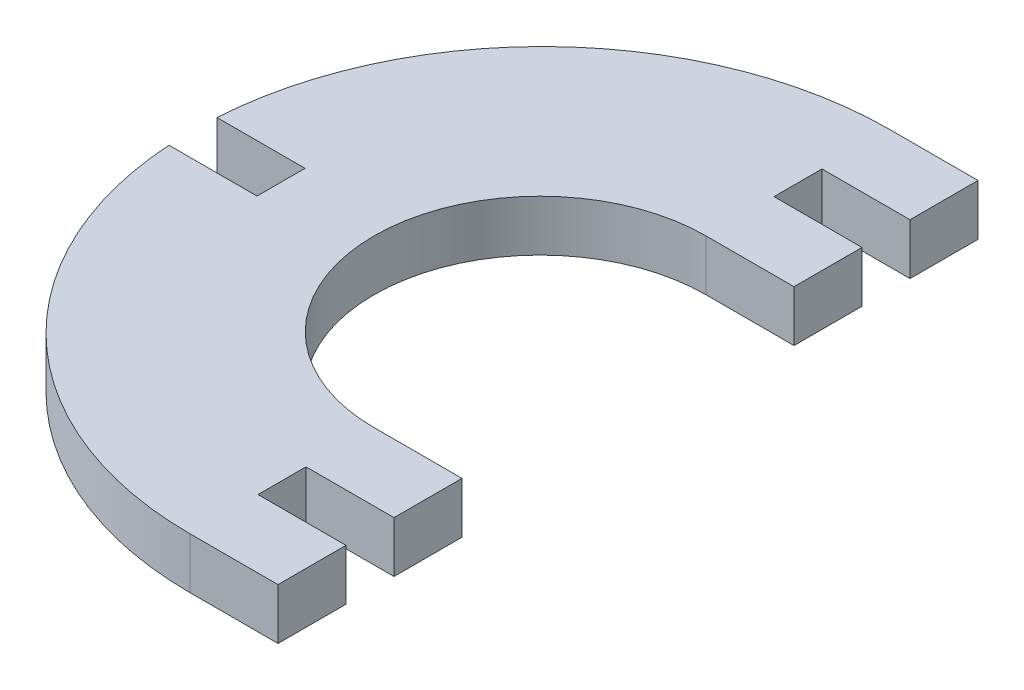
from build123d import *

# Parameters (mm, degrees)
SALIENTE_EXTRUIR1_DEPTH = 5.1


with BuildPart() as part:
    # Croquis1 → Saliente-Extruir1 (new body)
    with BuildSketch(Plane(origin=(0, 0, 0), x_dir=(1, 0, 0), z_dir=(0, 1, 0))):
        with BuildLine():
            Line((0, 0), (0, 6.8))
            Line((0, 6.8), (-8.8, 6.8))
            Line((-8.8, 6.8), (-8.8, 11.6))
            Line((-8.8, 11.6), (0, 11.6))
            Line((0, 11.6), (0, 18.4))
            Line((0, 18.4), (-8.8, 18.4))
            ThreePointArc((-8.8, 18.4), (-25.4, 35), (-8.8, 51.6))
            Line((-8.8, 51.6), (0, 51.6))
            Line((0, 51.6), (0, 58.4))
            Line((0, 58.4), (-8.8, 58.4))
            Line((-8.8, 58.4), (-8.8, 63.2))
            Line((-8.8, 63.2), (0, 63.2))
            Line((0, 63.2), (0, 70))
            Line((0, 70), (-8.8, 70))
            ThreePointArc((-8.8, 70), (-32.605724102, 60.57158363), (-43.5, 37.4))
            Line((-43.5, 37.4), (-34.7, 37.4))
            Line((-34.7, 37.4), (-34.7, 32.6))
            Line((-34.7, 32.6), (-43.5, 32.6))
            ThreePointArc((-43.5, 32.6), (-32.605724102, 9.42841637), (-8.8, 0))
            Line((-8.8, 0), (0, 0))
        make_face()
    extrude(amount=SALIENTE_EXTRUIR1_DEPTH)


solid = part.part
